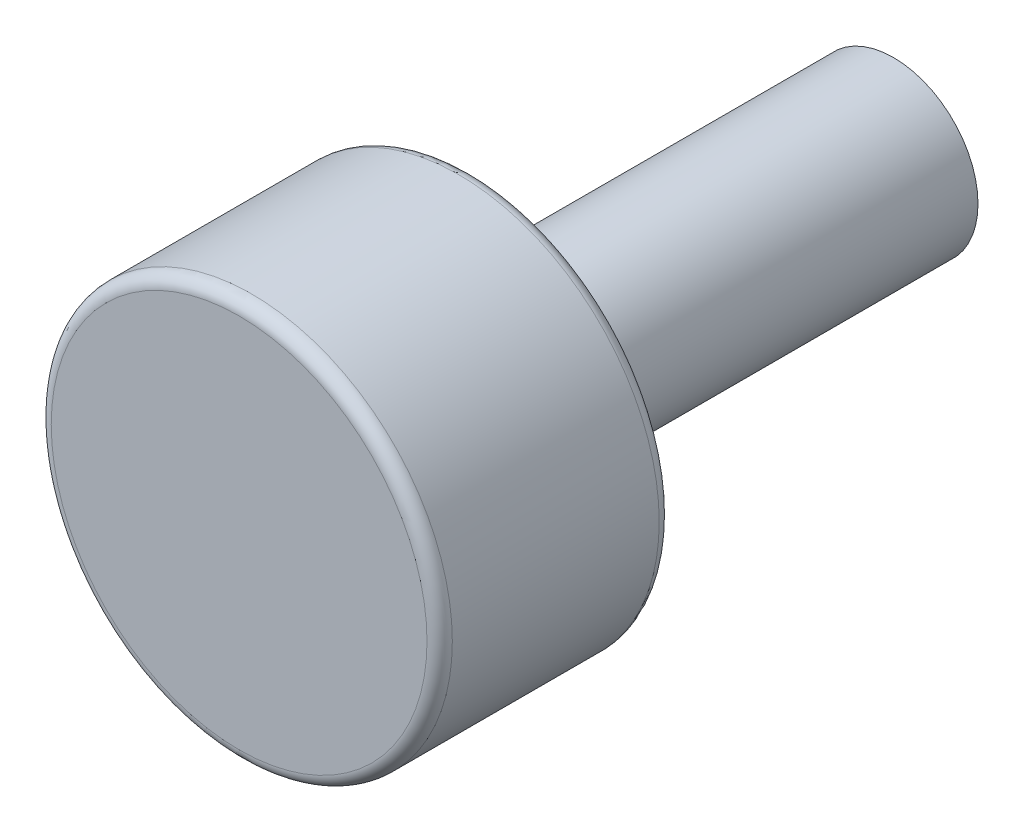
from build123d import *

# Parameters (mm, degrees)
SKETCH1_R           = 9.5
BOSS_EXTRUDE1_DEPTH = 11
SKETCH2_R           = 4
BOSS_EXTRUDE2_DEPTH = 20
FILLET1_R           = 0.6
FILLET2_R           = 0.6


with BuildPart() as part:
    # Sketch1 → Boss-Extrude1 (new body)
    with BuildSketch(Plane.XY):
        Circle(SKETCH1_R)
    extrude(amount=BOSS_EXTRUDE1_DEPTH)

    # Sketch2 → Boss-Extrude2 (add)
    with BuildSketch(Plane(origin=(0, 0, 0), x_dir=(-1, 0, 0), z_dir=(0, 0, -1))):
        Circle(SKETCH2_R)
    extrude(amount=BOSS_EXTRUDE2_DEPTH)

    # Fillet1
    fillet1_edges = [part.edges().sort_by_distance(p)[0] for p in [
        (-9.5, 0, 11),
    ]]
    fillet(fillet1_edges, radius=FILLET1_R)

    # Fillet2
    fillet2_edges = [part.edges().sort_by_distance(p)[0] for p in [
        (-9.5, 0, 0),
    ]]
    fillet(fillet2_edges, radius=FILLET2_R)


solid = part.part
